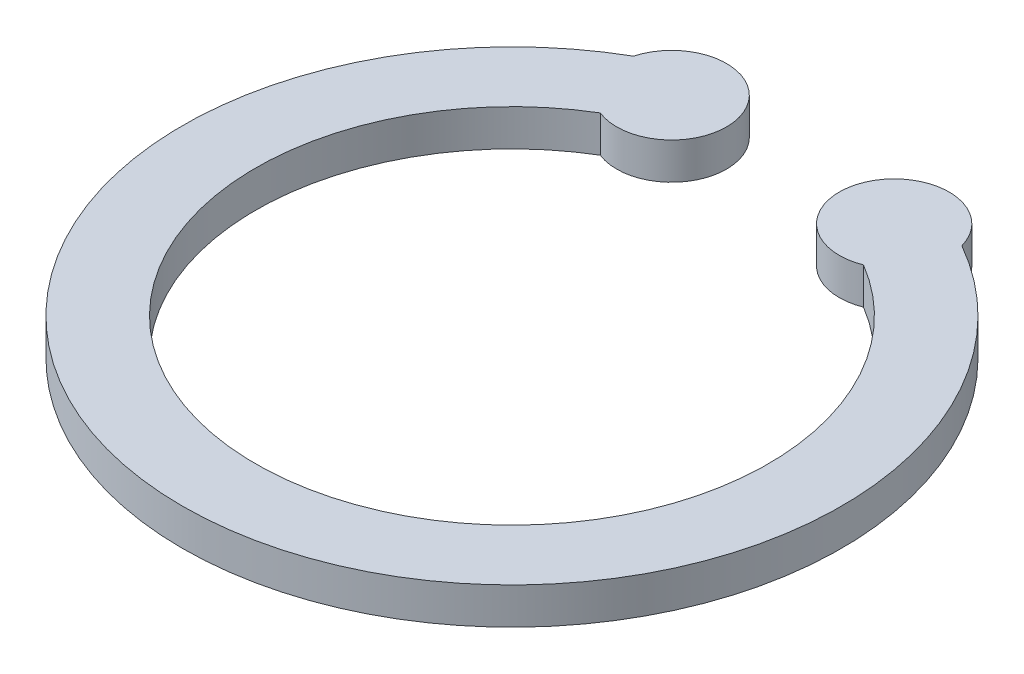
from build123d import *

# Parameters (mm, degrees)
BOSS_EXTRUDE1_DEPTH = 0.5


with BuildPart() as part:
    # Sketch1 → Boss-Extrude1 (new body)
    with BuildSketch(Plane(origin=(0, 0, 0), x_dir=(1, 0, 0), z_dir=(0, 1, 0))):
        with BuildLine():
            ThreePointArc((-1.797128778, 3.003386115), (0, -3.5), (1.797128778, 3.003386115))
            ThreePointArc((1.797128778, 3.003386115), (0.847429492, 4.03292135), (2.241942654, 3.901755135))
            ThreePointArc((2.241942654, 3.901755135), (0, -4.5), (-2.241942654, 3.901755135))
            ThreePointArc((-2.241942654, 3.901755135), (-0.847429492, 4.03292135), (-1.797128778, 3.003386115))
        make_face()
    extrude(amount=BOSS_EXTRUDE1_DEPTH)


solid = part.part
